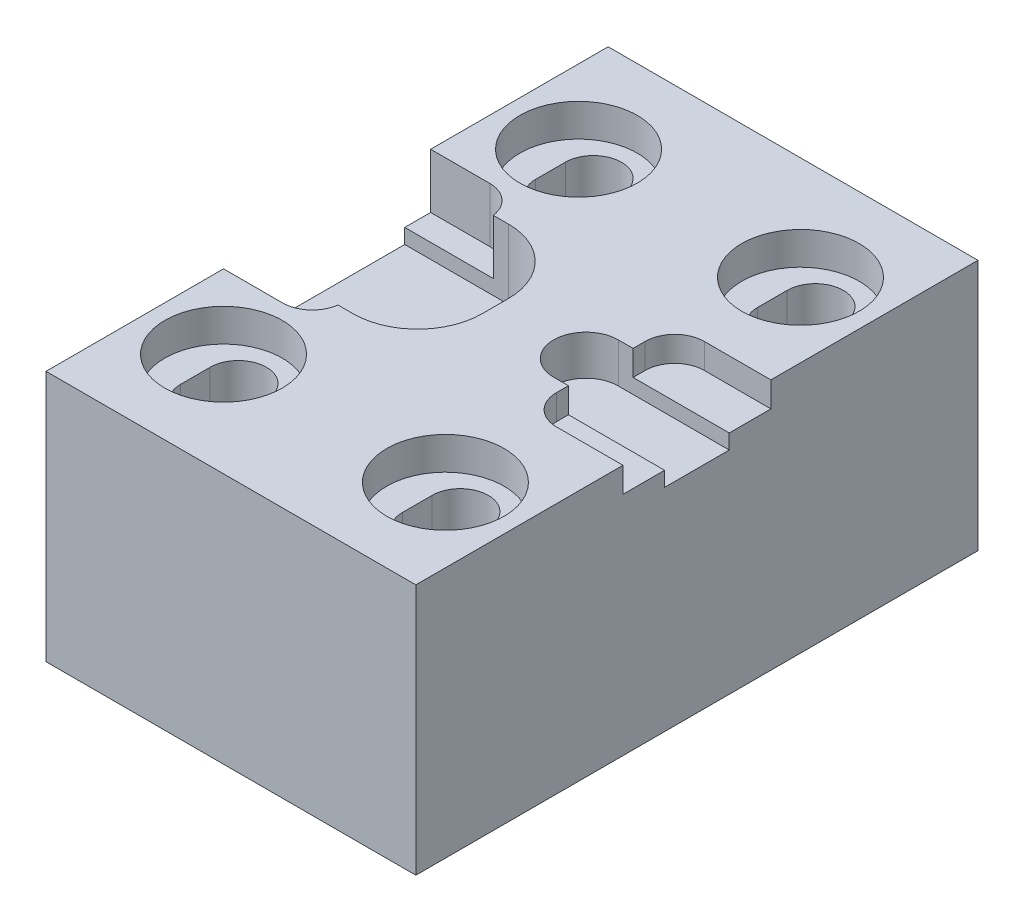
from build123d import *

# Parameters (mm, degrees)
SKETCH1_W                                           = 25
SKETCH1_H                                           = 38
BOSS_EXTRUDE1_DEPTH                                 = 17
CUT_EXTRUDE3_DEPTH                                  = 3.7
CUT_EXTRUDE4_DEPTH                                  = 1.7
CBORE_FOR_6_BINDING_HEAD_MACHINE_SCREW1_D           = 3.7973
CBORE_FOR_6_BINDING_HEAD_MACHINE_SCREW1_CBORE_D     = 7.9375
CBORE_FOR_6_BINDING_HEAD_MACHINE_SCREW1_CBORE_DEPTH = 2.2098
SKETCH12_W                                          = 1
SKETCH12_H                                          = 4.37
SKETCH12_W_2                                        = 6.5
CUT_EXTRUDE5_DEPTH                                  = 2.7
CUT_EXTRUDE6_DEPTH                                  = 4.7
CUT_EXTRUDE7_DEPTH                                  = 21682.908892909


with BuildPart() as part:
    # Sketch1 → Boss-Extrude1 (new body)
    with BuildSketch(Plane(origin=(0, 0, 0), x_dir=(1, 0, 0), z_dir=(0, 1, 0))):
        with Locations((-18481.446731235, 11298.191283293)):
            Rectangle(SKETCH1_W, SKETCH1_H)
    extrude(amount=BOSS_EXTRUDE1_DEPTH)

    # Sketch2 → Cut-Extrude3 (cut)
    with BuildSketch(Plane(origin=(0, 17, 0), x_dir=(1, 0, 0), z_dir=(0, 1, 0))):
        with BuildLine():
            Line((-18493.946731235, 11291.191283293), (-18489.946731235, 11291.191283293))
            ThreePointArc((-18489.946731235, 11291.191283293), (-18488.532517672, 11291.777069731), (-18487.946731235, 11293.191283293))
            Line((-18487.946731235, 11293.191283293), (-18487.946731235, 11303.191283293))
            ThreePointArc((-18487.946731235, 11303.191283293), (-18488.532517672, 11304.605496855), (-18489.946731235, 11305.191283293))
            Line((-18489.946731235, 11305.191283293), (-18493.946731235, 11305.191283293))
            Line((-18493.946731235, 11305.191283293), (-18493.946731235, 11291.191283293))
        make_face()
    extrude(amount=-CUT_EXTRUDE3_DEPTH, mode=Mode.SUBTRACT)

    # Sketch2_6 → Cut-Extrude4 (cut)
    with BuildSketch(Plane(origin=(0, 17, 0), x_dir=(1, 0, 0), z_dir=(0, 1, 0))):
        with BuildLine():
            Line((-18475.446731235, 11301.191283293), (-18475.446731235, 11295.191283293))
            ThreePointArc((-18475.446731235, 11295.191283293), (-18474.860944797, 11293.777069731), (-18473.446731235, 11293.191283293))
            Line((-18473.446731235, 11293.191283293), (-18468.946731235, 11293.191283293))
            Line((-18468.946731235, 11293.191283293), (-18468.946731235, 11303.191283293))
            Line((-18468.946731235, 11303.191283293), (-18473.446731235, 11303.191283293))
            ThreePointArc((-18473.446731235, 11303.191283293), (-18474.860944797, 11302.605496855), (-18475.446731235, 11301.191283293))
        make_face()
    extrude(amount=-CUT_EXTRUDE4_DEPTH, mode=Mode.SUBTRACT)

    # CBORE for _6 Binding Head Machine Screw1 (through all)
    with Locations(Plane(origin=(0, 17, 0), x_dir=(1, 0, 0), z_dir=(0, 1, 0))):
        with Locations((-18488.946731235, 11310.191283293), (-18473.946731235, 11310.191283293), (-18473.946731235, 11286.191283293), (-18488.946731235, 11286.191283293)):
            CounterBoreHole(CBORE_FOR_6_BINDING_HEAD_MACHINE_SCREW1_D / 2, CBORE_FOR_6_BINDING_HEAD_MACHINE_SCREW1_CBORE_D / 2, CBORE_FOR_6_BINDING_HEAD_MACHINE_SCREW1_CBORE_DEPTH)

    # Sketch12 → Cut-Extrude5 (cut)
    with BuildSketch(Plane(origin=(0, 17, 0), x_dir=(1, 0, 0), z_dir=(0, 1, 0))):
        with BuildLine():
            Line((-18476.446731235, 11300.376283293), (-18476.446731235, 11296.006283293))
            ThreePointArc((-18476.446731235, 11296.006283293), (-18478.631731235, 11298.191283293), (-18476.446731235, 11300.376283293))
        make_face()
        with Locations((-18475.946731235, 11298.191283293)):
            Rectangle(SKETCH12_W, SKETCH12_H)
        with Locations((-18472.196731235, 11298.191283293)):
            Rectangle(SKETCH12_W_2, SKETCH12_H)
    extrude(amount=-CUT_EXTRUDE5_DEPTH, mode=Mode.SUBTRACT)

    # Sketch13 → Cut-Extrude6 (cut)
    with BuildSketch(Plane(origin=(0, 17, 0), x_dir=(1, 0, 0), z_dir=(0, 1, 0))):
        with BuildLine():
            ThreePointArc((-18486.936731235, 11303.441283293), (-18483.853745669, 11302.164268859), (-18482.576731235, 11299.081283293))
            Line((-18482.576731235, 11299.081283293), (-18482.576731235, 11297.301283293))
            ThreePointArc((-18482.576731235, 11297.301283293), (-18483.853745669, 11294.218297727), (-18486.936731235, 11292.941283293))
            Line((-18486.936731235, 11292.941283293), (-18486.946731235, 11292.941283293))
            Line((-18486.946731235, 11292.941283293), (-18486.946731235, 11303.441283293))
            Line((-18486.946731235, 11303.441283293), (-18486.936731235, 11303.441283293))
        make_face()
        with BuildLine():
            ThreePointArc((-18487.946731235, 11303.191283293), (-18487.950656716, 11303.316529118), (-18487.962417752, 11303.441283293))
            Line((-18487.962417752, 11303.441283293), (-18493.946731235, 11303.441283293))
            Line((-18493.946731235, 11303.441283293), (-18493.946731235, 11292.941283293))
            Line((-18493.946731235, 11292.941283293), (-18487.962417752, 11292.941283293))
            ThreePointArc((-18487.962417752, 11292.941283293), (-18487.950656716, 11293.066037468), (-18487.946731235, 11293.191283293))
            Line((-18487.946731235, 11293.191283293), (-18487.946731235, 11303.191283293))
        make_face()
        with BuildLine():
            Line((-18486.946731235, 11292.941283293), (-18486.946731235, 11303.441283293))
            Line((-18486.946731235, 11303.441283293), (-18487.962417752, 11303.441283293))
            ThreePointArc((-18487.962417752, 11303.441283293), (-18487.950656716, 11303.316529118), (-18487.946731235, 11303.191283293))
            Line((-18487.946731235, 11303.191283293), (-18487.946731235, 11293.191283293))
            ThreePointArc((-18487.946731235, 11293.191283293), (-18487.950656716, 11293.066037468), (-18487.962417752, 11292.941283293))
            Line((-18487.962417752, 11292.941283293), (-18486.946731235, 11292.941283293))
        make_face()
    extrude(amount=-CUT_EXTRUDE6_DEPTH, mode=Mode.SUBTRACT)

    # Sketch14 → Cut-Extrude7 (cut, through all)
    with BuildSketch(Plane(origin=(0, 17, 0), x_dir=(1, 0, 0), z_dir=(0, 1, 0))):
        with BuildLine():
            Line((-18487.046731235, 11309.191283293), (-18487.046731235, 11311.191283293))
            ThreePointArc((-18487.046731235, 11311.191283293), (-18488.946731235, 11313.091283293), (-18490.846731235, 11311.191283293))
            Line((-18490.846731235, 11311.191283293), (-18490.846731235, 11309.191283293))
            ThreePointArc((-18490.846731235, 11309.191283293), (-18488.946731235, 11307.291283293), (-18487.046731235, 11309.191283293))
        make_face()
        with BuildLine():
            ThreePointArc((-18475.846731235, 11311.191283293), (-18473.946731235, 11313.091283293), (-18472.046731235, 11311.191283293))
            Line((-18472.046731235, 11311.191283293), (-18472.046731235, 11309.191283293))
            ThreePointArc((-18472.046731235, 11309.191283293), (-18473.946731235, 11307.291283293), (-18475.846731235, 11309.191283293))
            Line((-18475.846731235, 11309.191283293), (-18475.846731235, 11311.191283293))
        make_face()
        with BuildLine():
            ThreePointArc((-18487.046731235, 11285.191283293), (-18488.946731235, 11283.291283293), (-18490.846731235, 11285.191283293))
            Line((-18490.846731235, 11285.191283293), (-18490.846731235, 11287.191283293))
            ThreePointArc((-18490.846731235, 11287.191283293), (-18488.946731235, 11289.091283293), (-18487.046731235, 11287.191283293))
            Line((-18487.046731235, 11287.191283293), (-18487.046731235, 11285.191283293))
        make_face()
        with BuildLine():
            Line((-18475.846731235, 11287.191283293), (-18475.846731235, 11285.191283293))
            ThreePointArc((-18475.846731235, 11285.191283293), (-18473.946731235, 11283.291283293), (-18472.046731235, 11285.191283293))
            Line((-18472.046731235, 11285.191283293), (-18472.046731235, 11287.191283293))
            ThreePointArc((-18472.046731235, 11287.191283293), (-18473.946731235, 11289.091283293), (-18475.846731235, 11287.191283293))
        make_face()
    extrude(amount=-CUT_EXTRUDE7_DEPTH, mode=Mode.SUBTRACT)


solid = part.part
